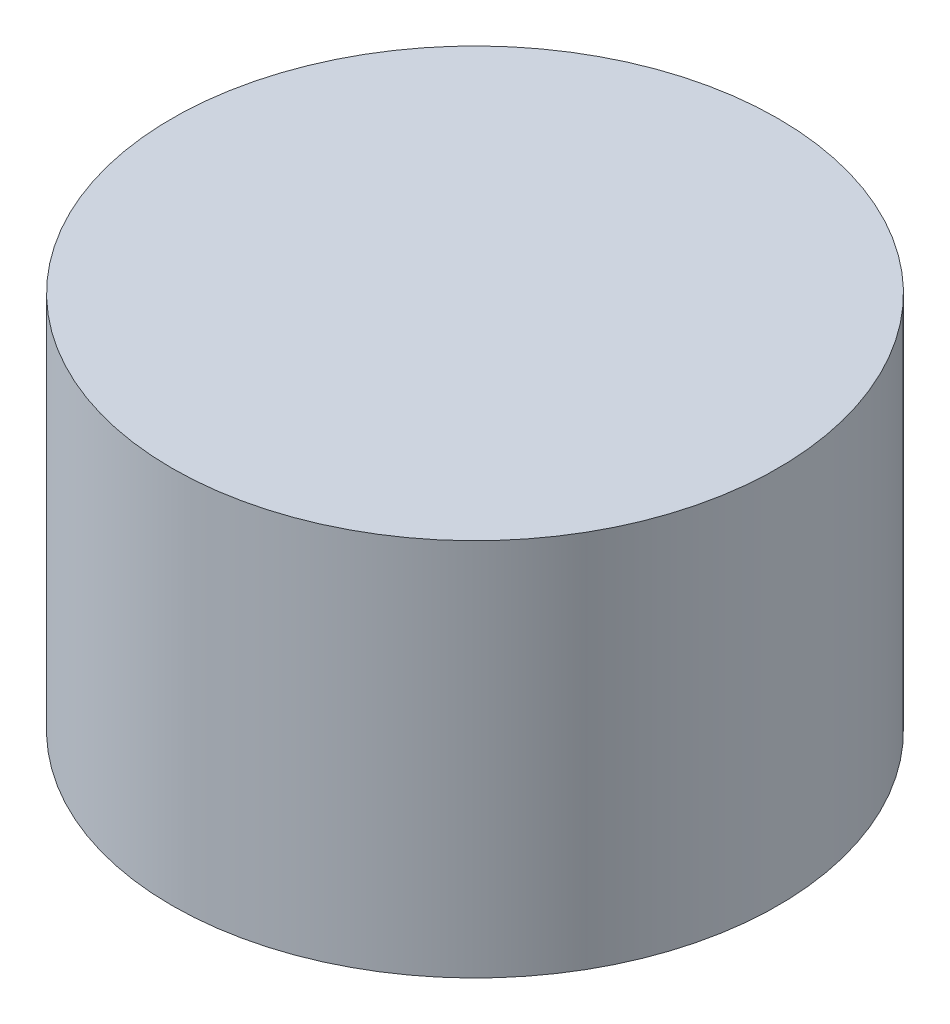
from build123d import *

# Parameters (mm, degrees)
SKETCH1_R           = 40
BOSS_EXTRUDE1_DEPTH = 50


with BuildPart() as part:
    # Sketch1 → Boss-Extrude1 (new body)
    with BuildSketch(Plane(origin=(0, 0, 0), x_dir=(1, 0, 0), z_dir=(0, 1, 0))):
        Circle(SKETCH1_R)
    extrude(amount=BOSS_EXTRUDE1_DEPTH)


solid = part.part
